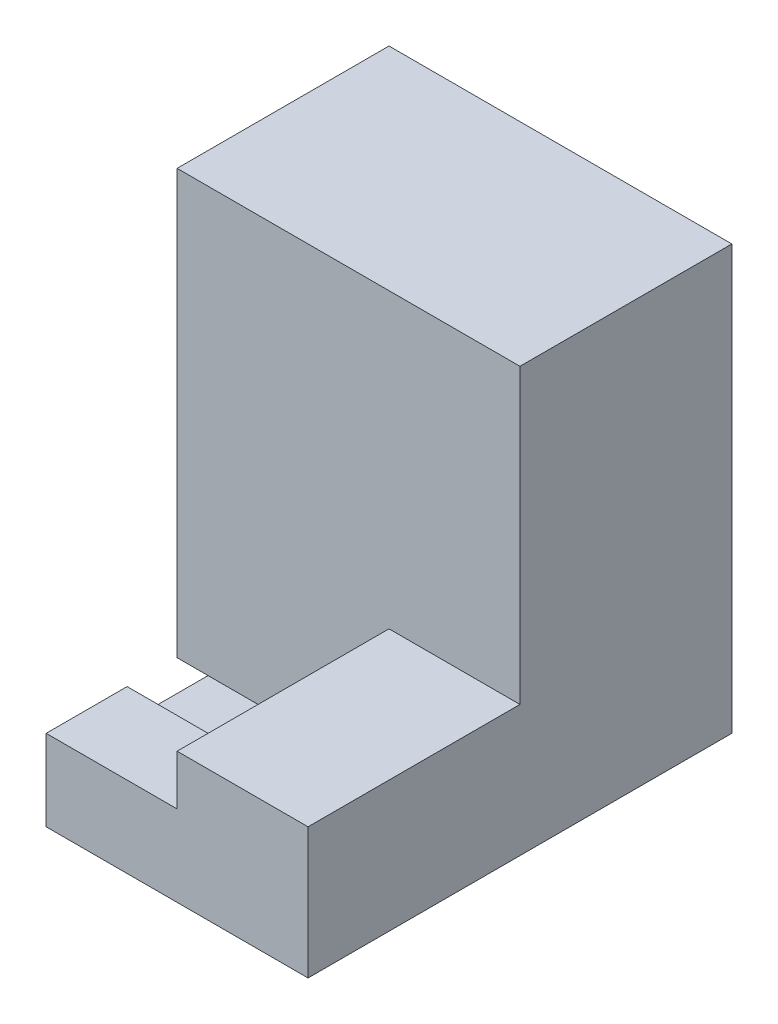
from build123d import *

# Parameters (mm, degrees)
BOSS_EXTRUDE1_DEPTH  = 1
BOSS_EXTRUDE2_DEPTH  = 2
BOSS_EXTRUDE3_DEPTH  = 3
BOSS_EXTRUDE4_DEPTH  = 5
BOSS_EXTRUDE5_DEPTH  = 8
BOSS_EXTRUDE6_DEPTH  = 13
BOSS_EXTRUDE7_DEPTH  = 21
BOSS_EXTRUDE8_DEPTH  = 34
BOSS_EXTRUDE9_DEPTH  = 55
BOSS_EXTRUDE10_DEPTH = 178


with BuildPart() as part:
    # Sketch1 → Boss-Extrude1 (new body)
    with BuildSketch(Plane(origin=(0, 0, 0), x_dir=(1, 0, 0), z_dir=(0, 1, 0))):
        Polygon((1, 0), (0, 0), (0, -0.997190903), (2.001284941, -0.997190903), (2.001284941, 1), (1, 1), align=None)
    extrude(amount=BOSS_EXTRUDE1_DEPTH)

    # Sketch1_3 → Boss-Extrude2 (add)
    with BuildSketch(Plane(origin=(0, 0, 0), x_dir=(1, 0, 0), z_dir=(0, 1, 0))):
        Polygon((-1, 1), (1, 1), (2.001284941, 1), (2.001284941, 2.997699814), (-1, 2.997699814), align=None)
    extrude(amount=BOSS_EXTRUDE2_DEPTH)

    # Sketch1_4 → Boss-Extrude3 (add)
    with BuildSketch(Plane(origin=(0, 0, 0), x_dir=(1, 0, 0), z_dir=(0, 1, 0))):
        Polygon((-1, -2), (-1, 1), (-1, 2.997699814), (-3.999741098, 2.997699814), (-3.999741098, -2), align=None)
    extrude(amount=BOSS_EXTRUDE3_DEPTH)

    # Sketch1_5 → Boss-Extrude4 (add)
    with BuildSketch(Plane(origin=(0, 0, 0), x_dir=(1, 0, 0), z_dir=(0, 1, 0))):
        Polygon((4, -2), (-1, -2), (-3.999741098, -2), (-3.999741098, -6.996932288), (4, -6.996932288), align=None)
    extrude(amount=BOSS_EXTRUDE4_DEPTH)

    # Sketch1_6 → Boss-Extrude5 (add)
    with BuildSketch(Plane(origin=(0, 0, 0), x_dir=(1, 0, 0), z_dir=(0, 1, 0))):
        Polygon((4, 6), (4, -2), (4, -6.996932288), (12.003242926, -6.996932288), (12.003242926, 6), align=None)
    extrude(amount=BOSS_EXTRUDE5_DEPTH)

    # Sketch1_7 → Boss-Extrude6 (add)
    with BuildSketch(Plane(origin=(0, 0, 0), x_dir=(1, 0, 0), z_dir=(0, 1, 0))):
        Polygon((-9, 6), (4, 6), (12.003242926, 6), (12.003242926, 18.995575243), (-9, 18.995575243), align=None)
    extrude(amount=BOSS_EXTRUDE6_DEPTH)

    # Sketch1_8 → Boss-Extrude7 (add)
    with BuildSketch(Plane(origin=(0, 0, 0), x_dir=(1, 0, 0), z_dir=(0, 1, 0))):
        Polygon((-9, -15), (-9, 6), (-9, 18.995575243), (-30.000063684, 18.995575243), (-30.000063684, -15), align=None)
    extrude(amount=BOSS_EXTRUDE7_DEPTH)

    # Sketch1_9 → Boss-Extrude8 (add)
    with BuildSketch(Plane(origin=(0, 0, 0), x_dir=(1, 0, 0), z_dir=(0, 1, 0))):
        Polygon((25, -15), (-9, -15), (-30.000063684, -15), (-30.000063684, -49.004916202), (25, -49.004916202), align=None)
    extrude(amount=BOSS_EXTRUDE8_DEPTH)

    # Sketch1_10 → Boss-Extrude9 (add)
    with BuildSketch(Plane(origin=(0, 0, 0), x_dir=(1, 0, 0), z_dir=(0, 1, 0))):
        Polygon((25, 40), (25, -15), (25, -49.004916202), (79.998803233, -49.004916202), (79.998803233, 40), align=None)
    extrude(amount=BOSS_EXTRUDE9_DEPTH)

    # Sketch1_12 → Boss-Extrude10 (add)
    with BuildSketch(Plane(origin=(0, 0, 0), x_dir=(1, 0, 0), z_dir=(0, 1, 0))):
        Polygon((-64, 40), (25, 40), (79.998803233, 40), (79.998803233, 128.996056825), (-64, 128.996056825), align=None)
    extrude(amount=BOSS_EXTRUDE10_DEPTH)


solid = part.part
